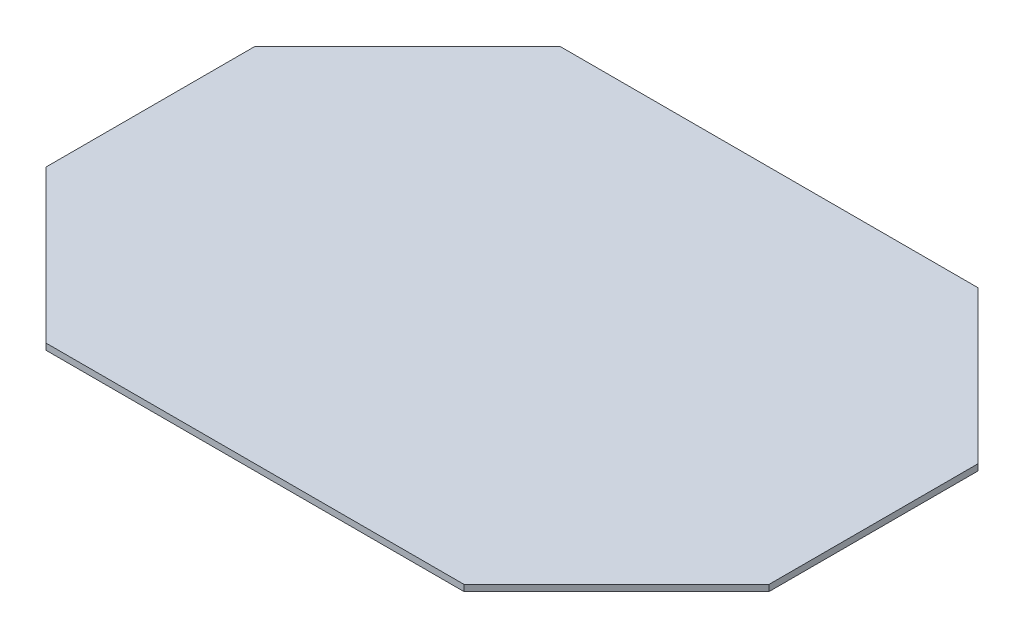
from build123d import *

# Parameters (mm, degrees)
EXTRUSION1_DEPTH = 3


with BuildPart() as part:
    # Esquisse1 → Extrusion1 (new body)
    with BuildSketch(Plane(origin=(0, 0, 0), x_dir=(1, 0, 0), z_dir=(0, 1, 0))):
        Polygon((0, 0), (0, 100), (72.916666667, 172.916666667), (272.916666667, 172.916666667), (345.833333333, 100), (345.833333333, 0), (272.916666667, -72.916666667), (72.916666667, -72.916666667), align=None)
    extrude(amount=EXTRUSION1_DEPTH)


solid = part.part
